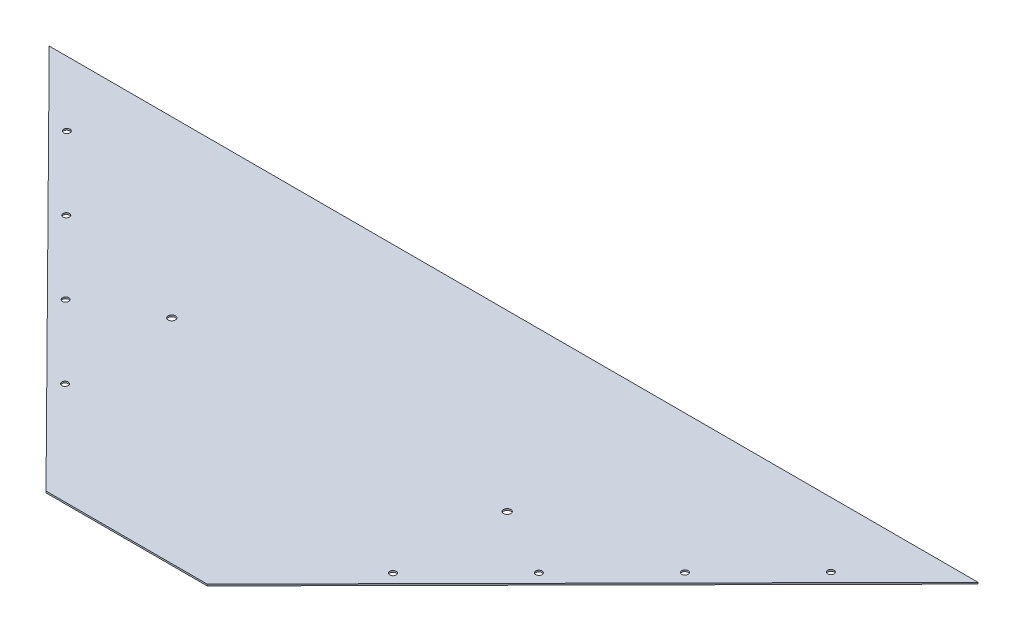
from build123d import *

# Parameters (mm, degrees)
BOSS_EXTRUDE1_DEPTH = 3.175
CUT_EXTRUDE1_REACH  = 5.175
SKETCH2_R           = 7.14375
SKETCH3_R           = 6.35
CUT_EXTRUDE2_DEPTH  = 4.175


with BuildPart() as part:
    # Sketch1 → Boss-Extrude1 (new body)
    with BuildSketch(Plane(origin=(0, 0, 0), x_dir=(1, 0, 0), z_dir=(0, 1, 0))):
        Polygon((0, 0), (317.5, 0), (1073.15, 762), (-755.65, 762), align=None)
    extrude(amount=BOSS_EXTRUDE1_DEPTH)

    # Sketch2 → Cut-Extrude1 (cut, up to next)
    with BuildSketch(Plane(origin=(0, 3.175, 0), x_dir=(1, 0, 0), z_dir=(0, 1, 0)), mode=Mode.PRIVATE) as cut_extrude1_sk1:
        with Locations((-171.45, 419.1)):
            Circle(SKETCH2_R)
    cut_extrude1_tool1 = extrude(cut_extrude1_sk1.sketch, amount=-CUT_EXTRUDE1_REACH, mode=Mode.PRIVATE) & part.part
    add(cut_extrude1_tool1.solids().sort_by_distance((-171.45, 3.175, -419.1))[0], mode=Mode.SUBTRACT)
    # Sketch2 → Cut-Extrude1 (cut, up to next)
    with BuildSketch(Plane(origin=(0, 3.175, 0), x_dir=(1, 0, 0), z_dir=(0, 1, 0)), mode=Mode.PRIVATE) as cut_extrude1_sk2:
        with Locations((488.95, 419.1)):
            Circle(SKETCH2_R)
    cut_extrude1_tool2 = extrude(cut_extrude1_sk2.sketch, amount=-CUT_EXTRUDE1_REACH, mode=Mode.PRIVATE) & part.part
    add(cut_extrude1_tool2.solids().sort_by_distance((488.95, 3.175, -419.1))[0], mode=Mode.SUBTRACT)

    # Sketch3 → Cut-Extrude2 (cut, through all)
    with BuildSketch(Plane(origin=(0, 3.175, 0), x_dir=(1, 0, 0), z_dir=(0, 1, 0))):
        with Locations((-593.402017408, 634.460857891)):
            Circle(SKETCH3_R)
        with Locations((-450.320360604, 490.176834222)):
            Circle(SKETCH3_R)
        with Locations((-307.238703799, 345.892810554)):
            Circle(SKETCH3_R)
        with Locations((-164.157046994, 201.608786885)):
            Circle(SKETCH3_R)
        with Locations((481.657046994, 201.608786885)):
            Circle(SKETCH3_R)
        with Locations((624.738703799, 345.892810554)):
            Circle(SKETCH3_R)
        with Locations((767.820360604, 490.176834222)):
            Circle(SKETCH3_R)
        with Locations((910.902017408, 634.460857891)):
            Circle(SKETCH3_R)
    extrude(amount=-CUT_EXTRUDE2_DEPTH, mode=Mode.SUBTRACT)


solid = part.part
